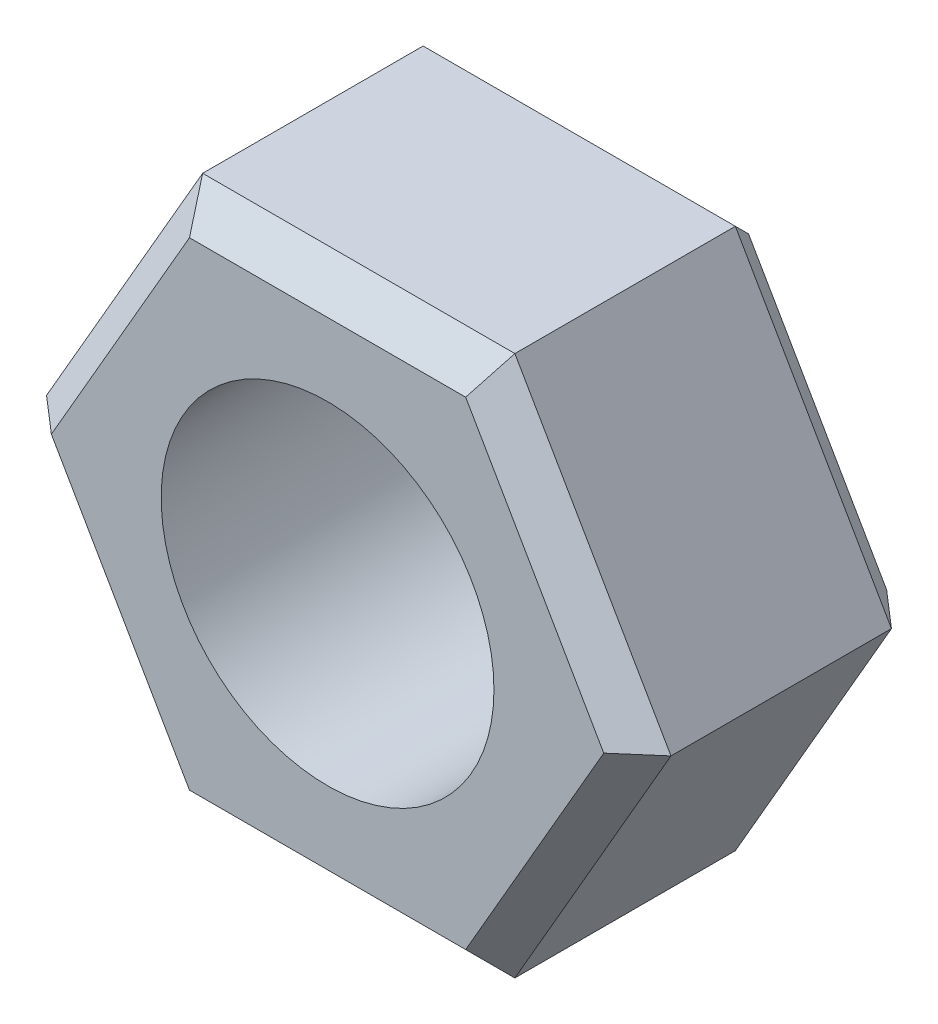
from build123d import *

# Parameters (mm, degrees)
SKETCH_1_R      = 4
EXTRUDE_1_DEPTH = 6.8
CHAMFER_1_SIZE  = 0.75


with BuildPart() as part:
    # Эскиз1 → Бобышка-Вытянуть1 (new body)
    with BuildSketch(Plane.XY):
        Polygon((3.75277675, -6.5), (7.505553499, 0), (3.75277675, 6.5), (-3.75277675, 6.5), (-7.505553499, 0), (-3.75277675, -6.5), align=None)
        Circle(SKETCH_1_R, mode=Mode.SUBTRACT)
    extrude(amount=EXTRUDE_1_DEPTH)

    # Фаска1
    chamfer_1_edges = [part.edges().sort_by_distance(p)[0] for p in [
        (5.629165125, 3.25, 6.8),
        (0, 6.5, 6.8),
        (-5.629165125, 3.25, 6.8),
        (-5.629165125, -3.25, 6.8),
        (0, -6.5, 6.8),
        (-5.629165125, -3.25, 0),
        (-5.629165125, 3.25, 0),
        (0, 6.5, 0),
        (5.629165125, 3.25, 0),
        (5.629165125, -3.25, 0),
        (0, -6.5, 0),
        (5.629165125, -3.25, 6.8),
    ]]
    chamfer(chamfer_1_edges, length=CHAMFER_1_SIZE)


solid = part.part
